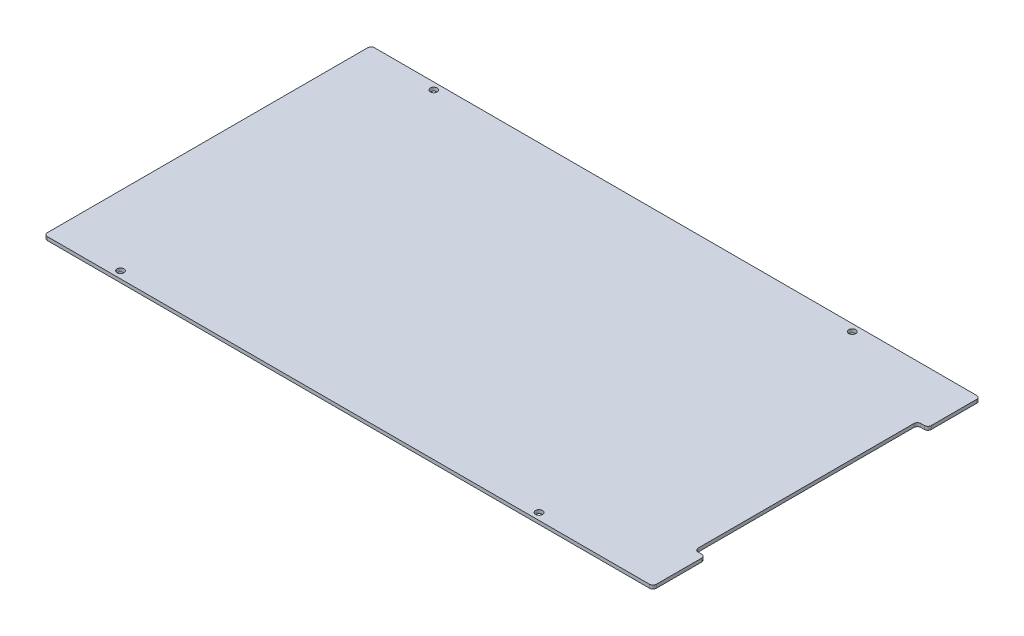
from build123d import *

# Parameters (mm, degrees)
SKETCH1_W                   = 555.625
SKETCH1_H                   = 298.45
BOSS_EXTRUDE1_DEPTH         = 3.175
SKETCH2_W                   = 9.525
SKETCH2_H                   = 203.2
CUT_EXTRUDE1_DEPTH          = 4.175
FILLET1_R                   = 3.175
F_1_4_0_25_DIAMETER_HOLE1_D = 6.35
FILLET2_R                   = 3.175


with BuildPart() as part:
    # Sketch1 → Boss-Extrude1 (new body)
    with BuildSketch(Plane(origin=(0, 0, 0), x_dir=(1, 0, 0), z_dir=(0, 1, 0))):
        Rectangle(SKETCH1_W, SKETCH1_H)
    extrude(amount=BOSS_EXTRUDE1_DEPTH)

    # Sketch2 → Cut-Extrude1 (cut, through all)
    with BuildSketch(Plane(origin=(0, 3.175, 0), x_dir=(1, 0, 0), z_dir=(0, 1, 0))):
        with Locations((273.05, 0)):
            Rectangle(SKETCH2_W, SKETCH2_H)
    extrude(amount=-CUT_EXTRUDE1_DEPTH, mode=Mode.SUBTRACT)

    # Fillet1
    fillet1_edges = [part.edges().sort_by_distance(p)[0] for p in [
        (268.2875, 1.5875, 101.6),
        (268.2875, 1.5875, -101.6),
    ]]
    fillet(fillet1_edges, radius=FILLET1_R)

    # 1/4 (0.25) Diameter Hole1 (through all)
    with Locations(Plane(origin=(0, 0, 0), x_dir=(-1, 0, 0), z_dir=(0, -1, 0))):
        with Locations((-167.5765, -142.875), (214.3125, -142.875)):
            f_1_4_0_25_diameter_hole1 = Hole(F_1_4_0_25_DIAMETER_HOLE1_D / 2)

    # Mirror1: 1/4 (0.25) Diameter Hole1 across plane
    add(f_1_4_0_25_diameter_hole1.mirror(Plane.XY), mode=Mode.SUBTRACT)

    # Fillet2
    fillet2_edges = [part.edges().sort_by_distance(p)[0] for p in [
        (277.8125, 1.5875, -101.6),
        (277.8125, 1.5875, 101.6),
        (277.8125, 1.5875, 149.225),
        (-277.8125, 1.5875, 149.225),
        (-277.8125, 1.5875, -149.225),
        (277.8125, 1.5875, -149.225),
    ]]
    fillet(fillet2_edges, radius=FILLET2_R)


solid = part.part
